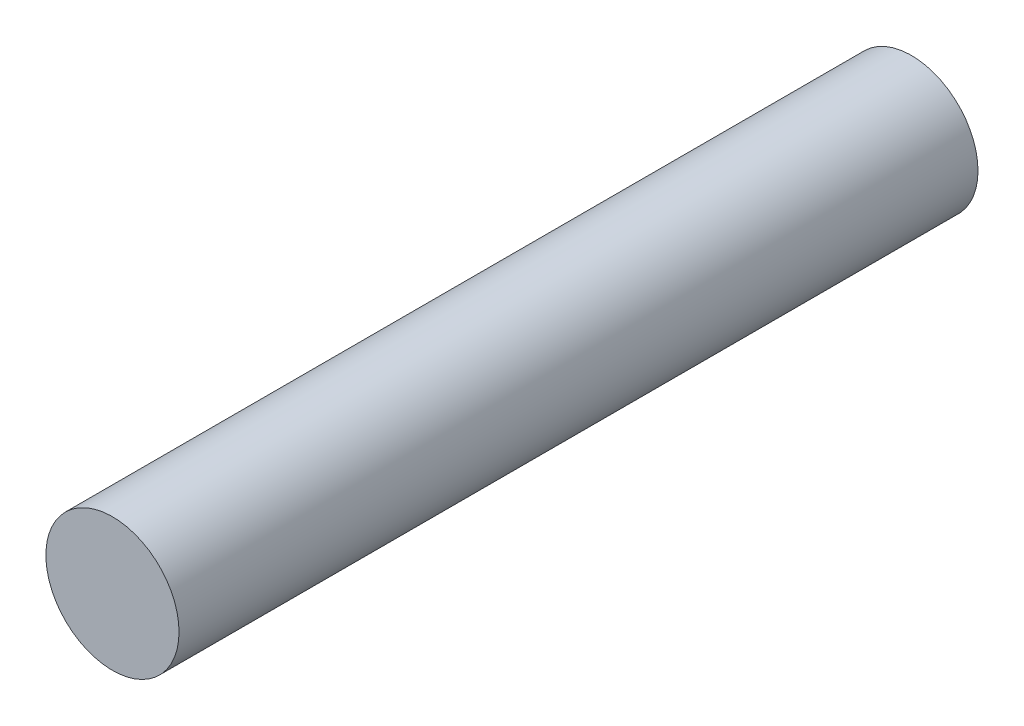
from build123d import *

# Parameters (mm, degrees)
SKETCH1_R           = 6.35
BOSS_EXTRUDE1_DEPTH = 76.2
SKETCH3_R           = 4.7625
CUT_EXTRUDE1_DEPTH  = 31.75


with BuildPart() as part:
    # Sketch1 → Boss-Extrude1 (new body)
    with BuildSketch(Plane.XY):
        with Locations((-5.914723807, 4.899935984)):
            Circle(SKETCH1_R)
    extrude(amount=BOSS_EXTRUDE1_DEPTH)

    # Sketch3 → Cut-Extrude1 (cut)
    with BuildSketch(Plane(origin=(0, 0, 0), x_dir=(-1, 0, 0), z_dir=(0, 0, -1))):
        with Locations((5.914723807, 4.899935984)):
            Circle(SKETCH3_R)
    extrude(amount=-CUT_EXTRUDE1_DEPTH, mode=Mode.SUBTRACT)


solid = part.part
